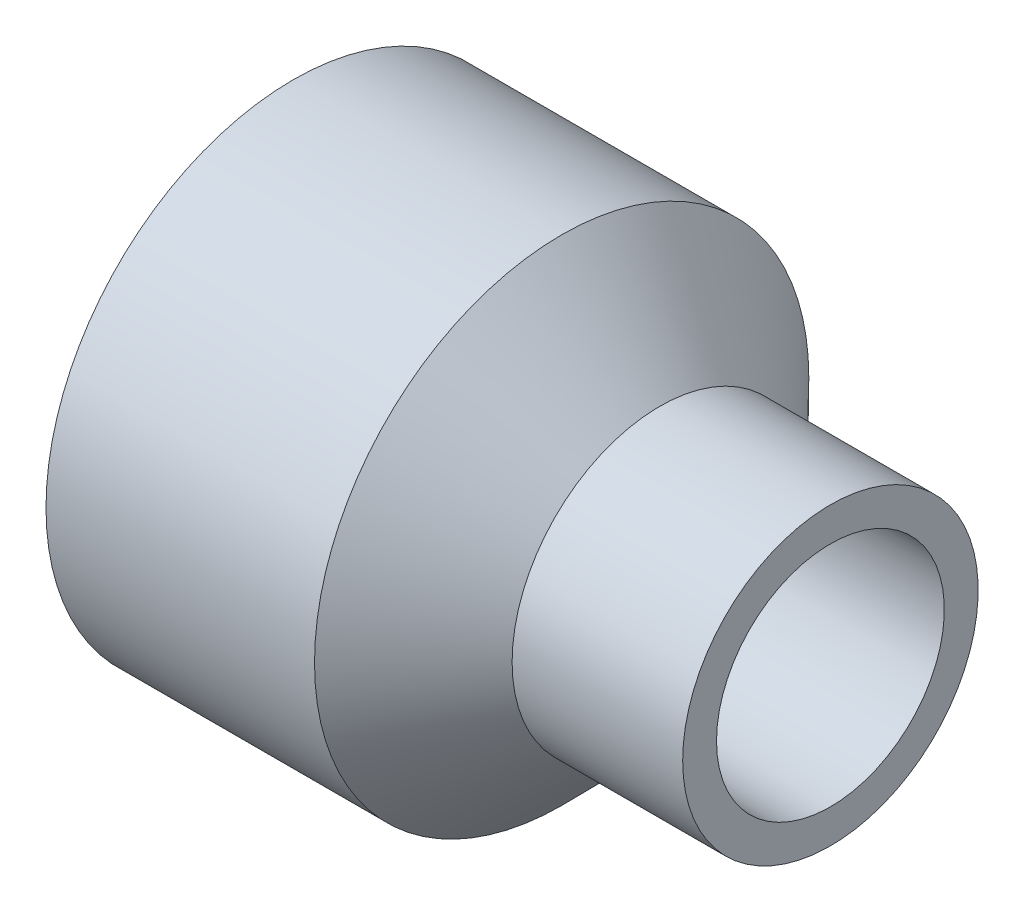
from build123d import *


with BuildPart() as part:
    # Sketch1 → Revolve1 (revolve)
    with BuildSketch(Plane.XY):
        Polygon((-39.6875, -36.5125), (-39.6875, -30.3149), (-2.38125, -30.0863), (8.843309719, -14.39545), (11.1125, -16.637), (39.6875, -16.8275), (39.6875, -21.828125), (14.487848147, -21.828125), (-0.017661179, -36.5125), align=None)
    revolve(axis=Axis((-39.6875, 0, 0), (1, 0, 0)))


solid = part.part
